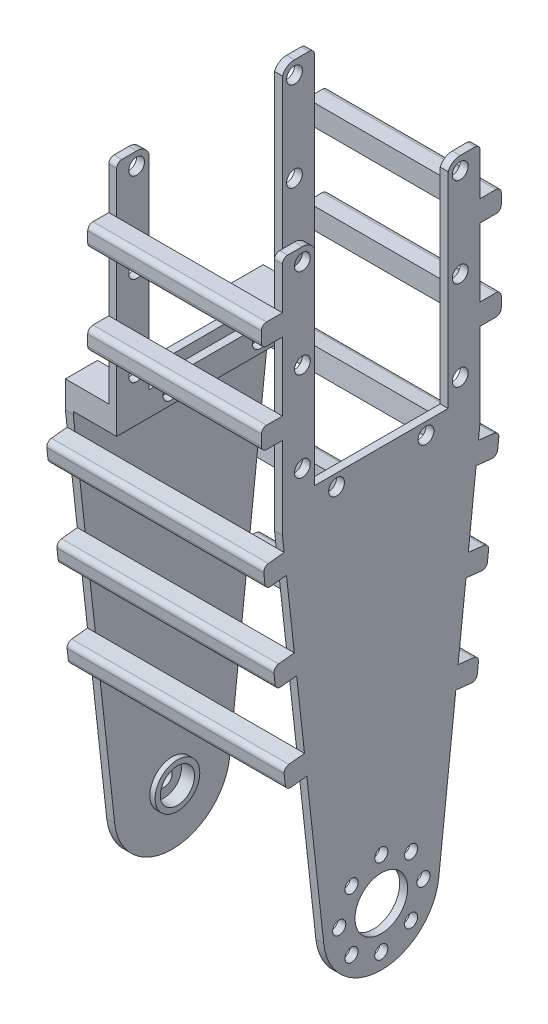
from build123d import *

# Parameters (mm, degrees)
SKETCH4_R            = 1.5
SKETCH4_W            = 25.4
SKETCH4_H            = 4.6
SKETCH4_W_2          = 6.1
SKETCH4_W_3          = 4
SKETCH4_H_2          = 4
BOSS_EXTRUDE1_DEPTH  = 1.5
SKETCH4_4_W          = 6.1
SKETCH4_4_H          = 4.6
BOSS_EXTRUDE3_DEPTH  = 6.75
BOSS_EXTRUDE4_START  = -8.25
SKETCH4_5_R          = 3.25
BOSS_EXTRUDE4_DEPTH  = 1.5
BOSS_EXTRUDE5_START  = -6.75
SKETCH4_7_R          = 4.25
SKETCH4_7_R_2        = 3.25
BOSS_EXTRUDE5_DEPTH  = 1
SKETCH5_R            = 5.25
SKETCH5_R_2          = 1.5
BOSS_EXTRUDE6_DEPTH  = 1
BOSS_EXTRUDE7_START  = 31.5
SKETCH4_9_R          = 1.25
SKETCH4_9_R_2        = 5
SKETCH4_9_R_3        = 1.5
SKETCH4_9_W          = 6.1
SKETCH4_9_H          = 4.6
SKETCH4_9_W_2        = 25.4
SKETCH4_9_W_3        = 4
SKETCH4_9_H_2        = 4
BOSS_EXTRUDE7_DEPTH  = 1.5
BOSS_EXTRUDE8_START  = 1.5
SKETCH4_11_W         = 4
SKETCH4_11_H         = 4
BOSS_EXTRUDE8_DEPTH  = 30
BOSS_EXTRUDE9_START  = -8.25
BOSS_EXTRUDE9_DEPTH  = 41.25
FILLET1_R            = 1
BOSS_EXTRUDE10_START = -41.25
BOSS_EXTRUDE10_DEPTH = 41.25
FILLET3_R            = 1


with BuildPart() as part:
    # Sketch4 → Boss-Extrude1 (new body)
    with BuildSketch(Plane(origin=(0, 0, 0), x_dir=(0, 0, -1), z_dir=(1, 0, 0))):
        with BuildLine():
            Line((12.7, 113.1), (12.7, 75.1))
            Line((12.7, 75.1), (18.8, 75.1))
            Line((18.8, 75.1), (18.8, 85.6))
            Line((18.8, 85.6), (18.8, 89.6))
            Line((18.8, 89.6), (18.8, 102.6))
            Line((18.8, 102.6), (18.8, 106.6))
            Line((18.8, 106.6), (18.8, 115.6))
            Line((18.8, 115.6), (15, 115.6))
            ThreePointArc((15, 115.6), (13.621502583, 115.185604198), (12.7, 114.079795897))
            Line((12.7, 114.079795897), (12.7, 113.1))
        make_face()
        with Locations((15, 79.1)):
            Circle(SKETCH4_R, mode=Mode.SUBTRACT)
        with Locations((15, 96.1)):
            Circle(SKETCH4_R, mode=Mode.SUBTRACT)
        with Locations((15, 113.1)):
            Circle(SKETCH4_R, mode=Mode.SUBTRACT)
        with Locations((0, 72.8)):
            Rectangle(SKETCH4_W, SKETCH4_H)
        with Locations((-8.5, 72.8)):
            Circle(SKETCH4_R, mode=Mode.SUBTRACT)
        with Locations((8.5, 72.8)):
            Circle(SKETCH4_R, mode=Mode.SUBTRACT)
        with BuildLine():
            Line((-18.8, 75.1), (-12.7, 75.1))
            Line((-12.7, 75.1), (-12.7, 113.1))
            Line((-12.7, 113.1), (-12.7, 114.079795897))
            ThreePointArc((-12.7, 114.079795897), (-13.621502583, 115.185604198), (-15, 115.6))
            Line((-15, 115.6), (-18.8, 115.6))
            Line((-18.8, 115.6), (-18.8, 106.6))
            Line((-18.8, 106.6), (-18.8, 102.6))
            Line((-18.8, 102.6), (-18.8, 89.6))
            Line((-18.8, 89.6), (-18.8, 85.6))
            Line((-18.8, 85.6), (-18.8, 75.1))
        make_face()
        with Locations((-15, 79.1)):
            Circle(SKETCH4_R, mode=Mode.SUBTRACT)
        with Locations((-15, 96.1)):
            Circle(SKETCH4_R, mode=Mode.SUBTRACT)
        with Locations((-15, 113.1)):
            Circle(SKETCH4_R, mode=Mode.SUBTRACT)
        with Locations((15.75, 72.8)):
            Rectangle(SKETCH4_W_2, SKETCH4_H)
        with Locations((-15.75, 72.8)):
            Rectangle(SKETCH4_W_2, SKETCH4_H)
        with Locations((-20.8, 87.6)):
            Rectangle(SKETCH4_W_3, SKETCH4_H_2)
        with Locations((-20.8, 104.6)):
            Rectangle(SKETCH4_W_3, SKETCH4_H_2)
        with Locations((20.8, 104.6)):
            Rectangle(SKETCH4_W_3, SKETCH4_H_2)
        with Locations((20.8, 87.6)):
            Rectangle(SKETCH4_W_3, SKETCH4_H_2)
    extrude(amount=BOSS_EXTRUDE1_DEPTH)

    # Sketch4_4 → Boss-Extrude3 (add)
    with BuildSketch(Plane(origin=(0, 0, 0), x_dir=(0, 0, -1), z_dir=(1, 0, 0))):
        with Locations((15.75, 72.8)):
            Rectangle(SKETCH4_4_W, SKETCH4_4_H)
        with Locations((-15.75, 72.8)):
            Rectangle(SKETCH4_4_W, SKETCH4_4_H)
    extrude(amount=-BOSS_EXTRUDE3_DEPTH)

    # Sketch4_5 → Boss-Extrude4 (add)
    with BuildSketch(Plane(origin=(0, 0, 0), x_dir=(0, 0, -1), z_dir=(1, 0, 0)).offset(BOSS_EXTRUDE4_START)):
        with BuildLine():
            Line((-12.7, 70.5), (-12.7, 75.1))
            Line((-12.7, 75.1), (-18.8, 75.1))
            Line((-18.8, 75.1), (-18.8, 70))
            Line((-18.8, 70), (-10.933485156, -1.207850299))
            ThreePointArc((-10.933485156, -1.207850299), (0, -11), (10.933485156, -1.207850299))
            Line((10.933485156, -1.207850299), (18.8, 70))
            Line((18.8, 70), (18.8, 75.1))
            Line((18.8, 75.1), (12.7, 75.1))
            Line((12.7, 75.1), (12.7, 70.5))
            Line((12.7, 70.5), (-12.7, 70.5))
        make_face()
        Circle(SKETCH4_5_R, mode=Mode.SUBTRACT)
    extrude(amount=BOSS_EXTRUDE4_DEPTH)

    # Sketch4_7 → Boss-Extrude5 (add)
    with BuildSketch(Plane(origin=(0, 0, 0), x_dir=(0, 0, -1), z_dir=(1, 0, 0)).offset(BOSS_EXTRUDE5_START)):
        Circle(SKETCH4_7_R)
        Circle(SKETCH4_7_R_2, mode=Mode.SUBTRACT)
    extrude(amount=BOSS_EXTRUDE5_DEPTH)

    # Sketch5 → Boss-Extrude6 (add)
    with BuildSketch(Plane.ZY.offset(8.25)):
        with Locations(Location((0, 0, 0), (0, 0, 180))):
            Circle(SKETCH5_R)
        Circle(SKETCH5_R_2, mode=Mode.SUBTRACT)
    extrude(amount=BOSS_EXTRUDE6_DEPTH)



with BuildPart() as body_2:
    # Sketch4_9 → Boss-Extrude7 (new body)
    with BuildSketch(Plane(origin=(0, 0, 0), x_dir=(0, 0, -1), z_dir=(1, 0, 0)).offset(BOSS_EXTRUDE7_START)):
        with BuildLine():
            Line((12.7, 70.5), (-12.7, 70.5))
            Line((-12.7, 70.5), (-18.8, 70.5))
            Line((-18.8, 70.5), (-18.8, 70))
            Line((-18.8, 70), (-18.467246252, 66.987906392))
            Line((-18.467246252, 66.987906392), (-18.028027961, 63.012093608))
            Line((-18.028027961, 63.012093608), (-14.600705998, 31.987906392))
            Line((-14.600705998, 31.987906392), (-14.161487708, 28.012093608))
            Line((-14.161487708, 28.012093608), (-10.933485156, -1.207850299))
            ThreePointArc((-10.933485156, -1.207850299), (0, -11), (10.933485156, -1.207850299))
            Line((10.933485156, -1.207850299), (14.161487708, 28.012093608))
            Line((14.161487708, 28.012093608), (14.600705998, 31.987906392))
            Line((14.600705998, 31.987906392), (18.028027961, 63.012093608))
            Line((18.028027961, 63.012093608), (18.467246252, 66.987906392))
            Line((18.467246252, 66.987906392), (18.8, 70))
            Line((18.8, 70), (18.8, 70.5))
            Line((18.8, 70.5), (12.7, 70.5))
        make_face()
        with Locations((-8, 0)):
            Circle(SKETCH4_9_R, mode=Mode.SUBTRACT)
        with Locations((-5.656854249, -5.656854249)):
            Circle(SKETCH4_9_R, mode=Mode.SUBTRACT)
        with Locations((-5.656854249, 5.656854249)):
            Circle(SKETCH4_9_R, mode=Mode.SUBTRACT)
        with Locations((0, -8)):
            Circle(SKETCH4_9_R, mode=Mode.SUBTRACT)
        with Locations((5.656854249, -5.656854249)):
            Circle(SKETCH4_9_R, mode=Mode.SUBTRACT)
        Circle(SKETCH4_9_R_2, mode=Mode.SUBTRACT)
        with Locations((8, 0)):
            Circle(SKETCH4_9_R, mode=Mode.SUBTRACT)
        with Locations((0, 8)):
            Circle(SKETCH4_9_R, mode=Mode.SUBTRACT)
        with Locations((5.656854249, 5.656854249)):
            Circle(SKETCH4_9_R, mode=Mode.SUBTRACT)
        with BuildLine():
            Line((-18.8, 75.1), (-12.7, 75.1))
            Line((-12.7, 75.1), (-12.7, 113.1))
            Line((-12.7, 113.1), (-12.7, 114.079795897))
            ThreePointArc((-12.7, 114.079795897), (-13.621502583, 115.185604198), (-15, 115.6))
            Line((-15, 115.6), (-18.8, 115.6))
            Line((-18.8, 115.6), (-18.8, 106.6))
            Line((-18.8, 106.6), (-18.8, 102.6))
            Line((-18.8, 102.6), (-18.8, 89.6))
            Line((-18.8, 89.6), (-18.8, 85.6))
            Line((-18.8, 85.6), (-18.8, 75.1))
        make_face()
        with Locations((-15, 79.1)):
            Circle(SKETCH4_9_R_3, mode=Mode.SUBTRACT)
        with Locations((-15, 96.1)):
            Circle(SKETCH4_9_R_3, mode=Mode.SUBTRACT)
        with Locations((-15, 113.1)):
            Circle(SKETCH4_9_R_3, mode=Mode.SUBTRACT)
        with Locations((-15.75, 72.8)):
            Rectangle(SKETCH4_9_W, SKETCH4_9_H)
        with Locations((15.75, 72.8)):
            Rectangle(SKETCH4_9_W, SKETCH4_9_H)
        with Locations((0, 72.8)):
            Rectangle(SKETCH4_9_W_2, SKETCH4_9_H)
        with Locations((-8.5, 72.8)):
            Circle(SKETCH4_9_R_3, mode=Mode.SUBTRACT)
        with Locations((8.5, 72.8)):
            Circle(SKETCH4_9_R_3, mode=Mode.SUBTRACT)
        with BuildLine():
            Line((12.7, 113.1), (12.7, 75.1))
            Line((12.7, 75.1), (18.8, 75.1))
            Line((18.8, 75.1), (18.8, 85.6))
            Line((18.8, 85.6), (18.8, 89.6))
            Line((18.8, 89.6), (18.8, 102.6))
            Line((18.8, 102.6), (18.8, 106.6))
            Line((18.8, 106.6), (18.8, 115.6))
            Line((18.8, 115.6), (15, 115.6))
            ThreePointArc((15, 115.6), (13.621502583, 115.185604198), (12.7, 114.079795897))
            Line((12.7, 114.079795897), (12.7, 113.1))
        make_face()
        with Locations((15, 79.1)):
            Circle(SKETCH4_9_R_3, mode=Mode.SUBTRACT)
        with Locations((15, 96.1)):
            Circle(SKETCH4_9_R_3, mode=Mode.SUBTRACT)
        with Locations((15, 113.1)):
            Circle(SKETCH4_9_R_3, mode=Mode.SUBTRACT)
        with Locations((-20.8, 104.6)):
            Rectangle(SKETCH4_9_W_3, SKETCH4_9_H_2)
        with Locations((-20.8, 87.6)):
            Rectangle(SKETCH4_9_W_3, SKETCH4_9_H_2)
        with Locations((20.8, 104.6)):
            Rectangle(SKETCH4_9_W_3, SKETCH4_9_H_2)
        with Locations((20.8, 87.6)):
            Rectangle(SKETCH4_9_W_3, SKETCH4_9_H_2)
    extrude(amount=BOSS_EXTRUDE7_DEPTH)


with BuildPart() as part_1:
    add(part.part)

    add(body_2.part)  # Boss-Extrude8 merges body 2
    # Sketch4_11 → Boss-Extrude8 (add)
    with BuildSketch(Plane(origin=(0, 0, 0), x_dir=(0, 0, -1), z_dir=(1, 0, 0)).offset(BOSS_EXTRUDE8_START)):
        with Locations((-20.8, 87.6)):
            Rectangle(SKETCH4_11_W, SKETCH4_11_H)
        with Locations((-20.8, 104.6)):
            Rectangle(SKETCH4_11_W, SKETCH4_11_H)
        with Locations((20.8, 104.6)):
            Rectangle(SKETCH4_11_W, SKETCH4_11_H)
        with Locations((20.8, 87.6)):
            Rectangle(SKETCH4_11_W, SKETCH4_11_H)
    extrude(amount=BOSS_EXTRUDE8_DEPTH)

    # Sketch4_12 → Boss-Extrude9 (add)
    with BuildSketch(Plane(origin=(0, 0, 0), x_dir=(0, 0, -1), z_dir=(1, 0, 0)).offset(BOSS_EXTRUDE9_START)):
        Polygon((-14.161487708, 28.012093608), (-14.600705998, 31.987906392), (-18.576518782, 31.548688101), (-18.137300492, 27.572875317), align=None)
        Polygon((22.443059036, 66.548688101), (18.467246252, 66.987906392), (18.028027961, 63.012093608), (22.003840745, 62.572875317), align=None)
        Polygon((-18.028027961, 63.012093608), (-18.467246252, 66.987906392), (-22.443059036, 66.548688101), (-22.003840745, 62.572875317), align=None)
        Polygon((18.576518782, 31.548688101), (14.600705998, 31.987906392), (14.161487708, 28.012093608), (18.137300492, 27.572875317), align=None)
    extrude(amount=BOSS_EXTRUDE9_DEPTH)

    # Fillet1
    fillet1_edges = [part_1.edges().sort_by_distance(p)[0] for p in [
        (32.25, 115.6, 18.8),
        (32.25, 115.6, -18.8),
        (12.375, 31.548688101, 18.576518782),
        (12.375, 27.572875317, 18.137300492),
        (12.375, 66.548688101, -22.443059036),
        (12.375, 62.572875317, -22.003840745),
        (0.75, 115.6, -18.8),
        (12.375, 66.548688101, 22.443059036),
        (12.375, 62.572875317, 22.003840745),
        (0.75, 115.6, 18.8),
        (12.375, 31.548688101, -18.576518782),
        (12.375, 27.572875317, -18.137300492),
        (16.5, 89.6, 22.8),
        (16.5, 85.6, 22.8),
        (16.5, 106.6, 22.8),
        (16.5, 102.6, 22.8),
        (16.5, 102.6, -22.8),
        (16.5, 106.6, -22.8),
        (16.5, 85.6, -22.8),
        (16.5, 89.6, -22.8),
    ]]
    fillet(fillet1_edges, radius=FILLET1_R)

    # Sketch6 → Boss-Extrude10 (add)
    with BuildSketch(Plane(origin=(33, 0, 0), x_dir=(0, 0, -1), z_dir=(1, 0, 0)).offset(BOSS_EXTRUDE10_START)):
        Polygon((-16.533976125, 49.487906392), (-20.509788909, 49.048688101), (-20.070570619, 45.072875317), (-16.094757835, 45.512093608), align=None)
        Polygon((16.533976125, 49.487906392), (20.509788909, 49.048688101), (20.070570619, 45.072875317), (16.094757835, 45.512093608), align=None)
    extrude(amount=BOSS_EXTRUDE10_DEPTH)

    # Fillet3
    fillet3_edges = [part_1.edges().sort_by_distance(p)[0] for p in [
        (12.375, 45.072875317, 20.070570619),
        (12.375, 49.048688101, 20.509788909),
        (12.375, 49.048688101, -20.509788909),
        (12.375, 45.072875317, -20.070570619),
    ]]
    fillet(fillet3_edges, radius=FILLET3_R)


solid = part_1.part
